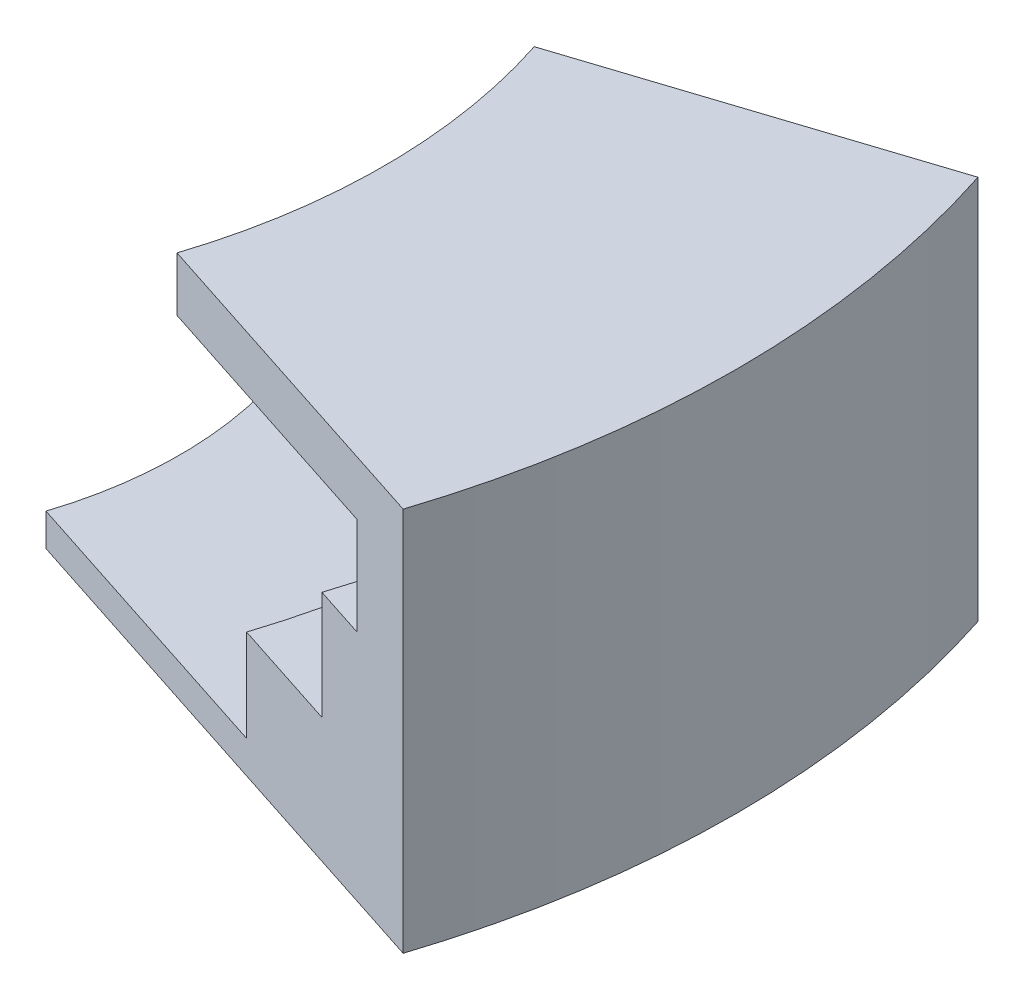
from build123d import *

# Parameters (mm, degrees)
REVOLVE1_ANGLE           = 18
REVOLVE1_OTHER_WAY_ANGLE = 18


with BuildPart() as part:
    # Sketch2 → Revolve1 (revolve)
    with BuildSketch(Plane.XY):
        Polygon((10.35, 112.53957189), (19, 112.53957189), (19, 115.08957189), (22.25, 115.08957189), (22.25, 118.08957189), (23.75, 118.08957189), (23.75, 120.78957189), (16, 120.78957189), (16, 122.28957189), (25.75, 122.28957189), (25.75, 111.63957189), (10.35, 111.63957189), align=None)
    revolve(axis=Axis((0, -1000, 0), (0, 1, 0)), revolution_arc=REVOLVE1_ANGLE)

    # Sketch2 → Revolve1 other way (revolve)
    with BuildSketch(Plane.XY):
        Polygon((10.35, 112.53957189), (19, 112.53957189), (19, 115.08957189), (22.25, 115.08957189), (22.25, 118.08957189), (23.75, 118.08957189), (23.75, 120.78957189), (16, 120.78957189), (16, 122.28957189), (25.75, 122.28957189), (25.75, 111.63957189), (10.35, 111.63957189), align=None)
    revolve(axis=Axis((0, -1000, 0), (0, -1, 0)), revolution_arc=REVOLVE1_OTHER_WAY_ANGLE)


solid = part.part
